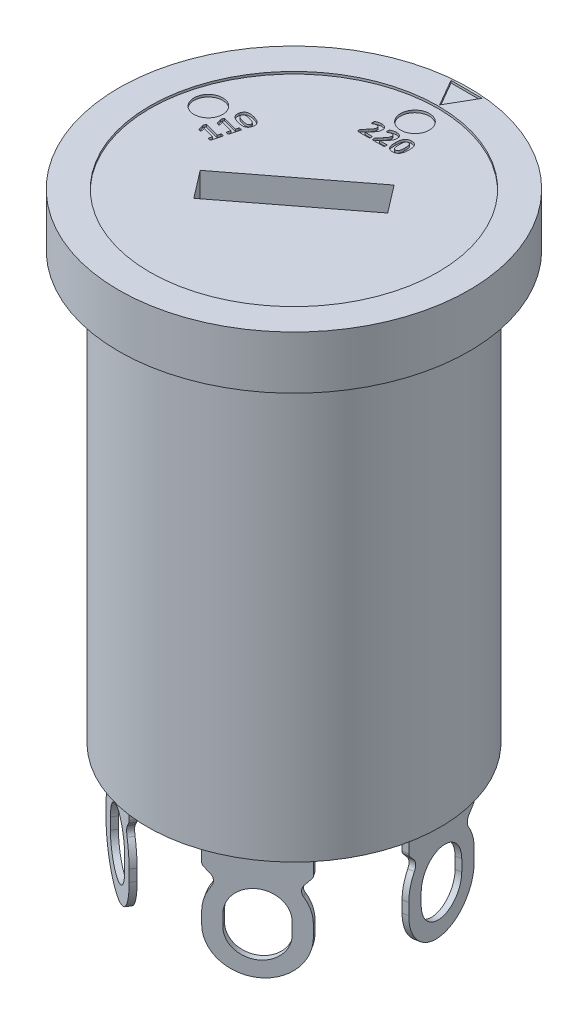
from build123d import *

# Parameters (mm, degrees)
SKETCH1_R                = 7.6
BOSS_EXTRUDE1_DEPTH      = 1.15
SKETCH2_R                = 6.35
BOSS_EXTRUDE2_DEPTH      = 18.5
BOSS_EXTRUDE3_DEPTH      = 5
CUT_EXTRUDE1_DEPTH       = 0.25
FILLET1_R                = 0.2
CIRPATTERN1_COUNT        = 4
CIRPATTERN1_ANGLE        = 200
FILLET1_OF_CIRPATTERN1_R = 0.2
SKETCH5_R                = 6.25
CUT_EXTRUDE2_DEPTH       = 0.1
CUT_EXTRUDE3_DEPTH       = 3
SKETCH7_R                = 0.625
CUT_EXTRUDE4_DEPTH       = 0.1


with BuildPart() as part:
    # Sketch1 → Boss-Extrude1 (new body, symmetric)
    with BuildSketch(Plane(origin=(0, 0, 0), x_dir=(1, 0, 0), z_dir=(0, 1, 0))):
        Circle(SKETCH1_R)
    extrude(amount=BOSS_EXTRUDE1_DEPTH, both=True)

    # Sketch2 → Boss-Extrude2 (add)
    with BuildSketch(Plane.XZ.offset(1.15)):
        Circle(SKETCH2_R)
    extrude(amount=BOSS_EXTRUDE2_DEPTH)

    # Sketch3 → Boss-Extrude3 (add)
    with BuildSketch(Plane.XZ.offset(19.65)):
        Polygon((-5.137178524, -2.682819749), (-4.890976586, -2.639407705), (-5.498745208, 0.807419431), (-5.744947146, 0.764007386), align=None)
    boss_extrude3 = extrude(amount=BOSS_EXTRUDE3_DEPTH)

    # Sketch4 → Cut-Extrude1 (cut)
    with BuildSketch(Plane(origin=(-5.441062835, 0, -0.959406182), x_dir=(-0.173648178, 0, 0.984807753), z_dir=(-0.984807753, 0, -0.173648178))):
        with BuildLine():
            Line((-1.084702388, -22.4), (-1.084702388, -22.9))
            ThreePointArc((-1.084702388, -22.9), (0, -23.984702388), (1.084702388, -22.9))
            Line((1.084702388, -22.9), (1.084702388, -22.4))
            ThreePointArc((1.084702388, -22.4), (0, -21.315297612), (-1.084702388, -22.4))
        make_face()
        with BuildLine():
            Line((1.75, -20.65), (1.474258984, -20.960255312))
            ThreePointArc((1.474258984, -20.960255312), (1.381845573, -21.181807831), (1.445322291, -21.413316933))
            ThreePointArc((1.445322291, -21.413316933), (1.672096589, -21.883673557), (1.75, -22.4))
            Line((1.75, -22.4), (1.75, -20.65))
        make_face()
        with BuildLine():
            Line((-1.75, -20.65), (-1.75, -22.4))
            ThreePointArc((-1.75, -22.4), (-1.672096589, -21.883673557), (-1.445322291, -21.413316933))
            ThreePointArc((-1.445322291, -21.413316933), (-1.381845573, -21.181807831), (-1.474258984, -20.960255312))
            Line((-1.474258984, -20.960255312), (-1.75, -20.65))
        make_face()
        with BuildLine():
            Line((-1.75, -24.65), (1e-09, -24.65))
            ThreePointArc((1e-09, -24.65), (-1.237436867, -24.137436867), (-1.75, -22.9))
            Line((-1.75, -22.9), (-1.75, -24.65))
        make_face()
        with BuildLine():
            Line((1.75, -24.65), (1.75, -22.9))
            ThreePointArc((1.75, -22.9), (1.237436867, -24.137436867), (1e-09, -24.65))
            Line((1e-09, -24.65), (1.75, -24.65))
        make_face()
    cut_extrude1 = extrude(amount=-CUT_EXTRUDE1_DEPTH, mode=Mode.SUBTRACT)

    # Fillet1
    fillet1_edges = [part.edges().sort_by_distance(p)[0] for p in [
        (-5.014077555, -20.65, -2.661113727),
        (-5.621846177, -20.65, 0.785713408),
    ]]
    fillet(fillet1_edges, radius=FILLET1_R)

    # CirPattern1: Boss-Extrude3, Cut-Extrude1 ×4 about axis
    cirpattern1_axis = Axis((0, 0, 0), (0, 1, 0))
    for i in range(1, CIRPATTERN1_COUNT):
        add(boss_extrude3.rotate(cirpattern1_axis, i * CIRPATTERN1_ANGLE / (CIRPATTERN1_COUNT - 1)))
        add(cut_extrude1.rotate(cirpattern1_axis, i * CIRPATTERN1_ANGLE / (CIRPATTERN1_COUNT - 1)), mode=Mode.SUBTRACT)

    # Fillet1 of CirPattern1
    fillet1_of_cirpattern1_edges = [part.edges().sort_by_distance(p)[0] for p in [
        (-4.429452152, -20.65, 3.54999347),
        (-1.505244812, -20.65, 5.473274893),
        (1.505244812, -20.65, 5.473274893),
        (4.429452152, -20.65, 3.54999347),
        (5.621846177, -20.65, 0.785713408),
        (5.014077555, -20.65, -2.661113727),
    ]]
    fillet(fillet1_of_cirpattern1_edges, radius=FILLET1_OF_CIRPATTERN1_R)

    # Sketch5 → Cut-Extrude2 (cut)
    with BuildSketch(Plane(origin=(0, 1.15, 0), x_dir=(1, 0, 0), z_dir=(0, 1, 0))):
        Circle(SKETCH5_R)
        Polygon((0, 6.320577137), (0.675, 7.489711432), (-0.675, 7.489711432), align=None)
    extrude(amount=-CUT_EXTRUDE2_DEPTH, mode=Mode.SUBTRACT)

    # Sketch6 → Cut-Extrude3 (cut)
    with BuildSketch(Plane(origin=(0, 1.05, 0), x_dir=(1, 0, 0), z_dir=(0, 1, 0))):
        Polygon((-2.836631093, -1.231269282), (1.923488949, 2.421299292), (2.836631093, 1.231269282), (-1.923488949, -2.421299292), align=None)
    extrude(amount=-CUT_EXTRUDE3_DEPTH, mode=Mode.SUBTRACT)

    # Sketch7 → Cut-Extrude4 (cut)
    with BuildSketch(Plane(origin=(0, 1.05, 0), x_dir=(1, 0, 0), z_dir=(0, 1, 0))):
        with Locations((0, 5.25)):
            Circle(SKETCH7_R)
        with Locations((-5.071110588, 1.358799987)):
            Circle(SKETCH7_R)
        with BuildLine():
            add(Edge.make_bspline(
                [(-3.673085561, 1.940530135), (-3.658145348, 1.936361866), (-3.62903577, 1.928240392), (-3.587140018, 1.913867484), (-3.547928097, 1.89851542), (-3.511575049, 1.881700826), (-3.478072823, 1.863870231), (-3.447977591, 1.844082858), (-3.421184433, 1.822698939), (-3.397658418, 1.799740336), (-3.377767174, 1.774961081), (-3.36157215, 1.748492487), (-3.348974447, 1.720329943), (-3.34042885, 1.690303427), (-3.335541318, 1.658374888), (-3.335406929, 1.624403585), (-3.339403169, 1.588393369), (-3.345353228, 1.564209779), (-3.348435974, 1.551680181)],
                knots=[0, 0, 0, 0, 4.6523e-05, 9.0647e-05, 0.000132813, 0.000172799, 0.000210747, 0.000246562, 0.000280686, 0.000313445, 0.000344977, 0.000375756, 0.000406294, 0.000437234, 0.000469141, 0.000502885, 0.000538857, 0.000577533, 0.000577533, 0.000577533, 0.000577533], degree=3))
            add(Edge.make_bspline(
                [(-3.348435974, 1.551680181), (-3.352064065, 1.539188901), (-3.359036652, 1.515182742), (-3.373299262, 1.481967022), (-3.390115576, 1.453021031), (-3.409383257, 1.428206666), (-3.431253127, 1.407500672), (-3.455339805, 1.390398241), (-3.481682399, 1.376783431), (-3.510246865, 1.366742302), (-3.540959073, 1.360109383), (-3.573819393, 1.356338579), (-3.608856279, 1.355442546), (-3.646016296, 1.357890469), (-3.685217038, 1.362659999), (-3.726422704, 1.369959365), (-3.769716625, 1.378974096), (-3.799022984, 1.386556399), (-3.814071027, 1.390449712)],
                knots=[0, 0, 0, 0, 3.8995e-05, 7.4942e-05, 0.000108131, 0.00013918, 0.000168853, 0.000198154, 0.000227521, 0.000257518, 0.000288715, 0.000321587, 0.000356617, 0.000393706, 0.000433205, 0.000475034, 0.000519211, 0.000565835, 0.000565835, 0.000565835, 0.000565835], degree=3))
            add(Edge.make_bspline(
                [(-3.814071027, 1.390449712), (-3.828888353, 1.394622667), (-3.857809707, 1.402767694), (-3.899525369, 1.417131822), (-3.938709652, 1.432530519), (-3.975319199, 1.449204161), (-4.008850075, 1.467515988), (-4.039112318, 1.487389119), (-4.065972279, 1.50882869), (-4.089498367, 1.53178647), (-4.109388554, 1.556566148), (-4.125587596, 1.583033856), (-4.138170368, 1.611199513), (-4.146770474, 1.641205652), (-4.151434556, 1.673170986), (-4.151298891, 1.706990564), (-4.147588964, 1.742820952), (-4.141752087, 1.766830127), (-4.138720613, 1.779299666)],
                knots=[0, 0, 0, 0, 4.6173e-05, 9.0124e-05, 0.00013229, 0.000172442, 0.000210725, 0.000246792, 0.000280916, 0.000313675, 0.000345207, 0.000375987, 0.000406524, 0.000437464, 0.000469345, 0.000503087, 0.000538677, 0.000577135, 0.000577135, 0.000577135, 0.000577135], degree=3))
            add(Edge.make_bspline(
                [(-4.138720613, 1.779299666), (-4.13502552, 1.791791386), (-4.127928963, 1.815782177), (-4.113586713, 1.848983418), (-4.097132268, 1.878172674), (-4.077702101, 1.902951358), (-4.05591877, 1.923841367), (-4.031899459, 1.941084859), (-4.005618574, 1.95479833), (-3.977007787, 1.964740999), (-3.946295273, 1.971691424), (-3.913321809, 1.975154226), (-3.878295692, 1.975898339), (-3.841129703, 1.973292872), (-3.801977935, 1.968194002), (-3.76068497, 1.961341733), (-3.71746959, 1.951922273), (-3.688139492, 1.944394058), (-3.673085561, 1.940530135)],
                knots=[0, 0, 0, 0, 3.905e-05, 7.4997e-05, 0.000108252, 0.000139301, 0.0001691, 0.000198507, 0.000227712, 0.000257709, 0.000289124, 0.000321975, 0.000357001, 0.000394101, 0.000433622, 0.000475421, 0.000519636, 0.00056626, 0.00056626, 0.00056626, 0.00056626], degree=3))
        make_face()
        with BuildLine():
            add(Edge.make_bspline(
                [(-3.707556781, 1.78112354), (-3.716367172, 1.783452413), (-3.733474209, 1.787974358), (-3.758434878, 1.794244062), (-3.781995581, 1.799464632), (-3.804033525, 1.804154135), (-3.824754464, 1.807659378), (-3.844091356, 1.811028027), (-3.862329119, 1.812836745), (-3.88411902, 1.814850337), (-3.908651563, 1.815597112), (-3.93490456, 1.813527346), (-3.957384849, 1.80896228), (-3.975917459, 1.800584592), (-3.991020091, 1.789392987), (-4.002808988, 1.775296999), (-4.011409801, 1.758422332), (-4.015133903, 1.746114382), (-4.017068212, 1.739721599)],
                knots=[0, 0, 0, 0, 2.7339e-05, 5.3084e-05, 7.7199e-05, 9.9734e-05, 0.000120665, 0.000140245, 0.000158593, 0.000175618, 0.000205903, 0.000232076, 0.00025451, 0.000274344, 0.000292583, 0.000310448, 0.000328966, 0.00034898, 0.00034898, 0.00034898, 0.00034898], degree=3))
            add(Edge.make_bspline(
                [(-4.017068212, 1.739721599), (-4.018404092, 1.734095858), (-4.020980447, 1.723246157), (-4.021794628, 1.706995335), (-4.02053717, 1.691597989), (-4.01616237, 1.677188935), (-4.009462827, 1.663554763), (-4.000128582, 1.650827817), (-3.988765504, 1.638419455), (-3.974672369, 1.627020605), (-3.95833926, 1.615993361), (-3.939509689, 1.60582433), (-3.91856731, 1.595654744), (-3.895205433, 1.58607251), (-3.869440215, 1.576908954), (-3.841562776, 1.567554024), (-3.811421877, 1.558493147), (-3.790553585, 1.552676331), (-3.779782194, 1.549673919)],
                knots=[0, 0, 0, 0, 1.7312e-05, 3.3388e-05, 4.8597e-05, 6.3428e-05, 7.8274e-05, 9.3963e-05, 0.000110613, 0.000128617, 0.000148194, 0.000169665, 0.00019275, 0.000218018, 0.000245365, 0.00027478, 0.000306225, 0.000339771, 0.000339771, 0.000339771, 0.000339771], degree=3))
            add(Edge.make_bspline(
                [(-3.779782194, 1.549673919), (-3.76672587, 1.546271163), (-3.741710461, 1.539751613), (-3.705720592, 1.531361061), (-3.673013368, 1.524691885), (-3.643500995, 1.519900578), (-3.616853915, 1.516680765), (-3.592858574, 1.515157952), (-3.571331615, 1.515236159), (-3.552268604, 1.516977086), (-3.535370946, 1.520332502), (-3.520712698, 1.525633862), (-3.508007074, 1.532392328), (-3.497348135, 1.5409295), (-3.488703373, 1.551338063), (-3.481183987, 1.562989109), (-3.475135098, 1.576289164), (-3.472285577, 1.585808257), (-3.470817925, 1.590711086)],
                knots=[0, 0, 0, 0, 4.0476e-05, 7.7551e-05, 0.000110852, 0.000140596, 0.000167224, 0.000191343, 0.000212683, 0.000231739, 0.000248694, 0.000264214, 0.000278334, 0.000291693, 0.000304888, 0.00031875, 0.000333196, 0.000348538, 0.000348538, 0.000348538, 0.000348538], degree=3))
            add(Edge.make_bspline(
                [(-3.470817925, 1.590711086), (-3.469146185, 1.598087799), (-3.465950071, 1.612190956), (-3.466632992, 1.633375654), (-3.471359248, 1.653117435), (-3.480915769, 1.671340846), (-3.494507099, 1.688446326), (-3.512865608, 1.703844069), (-3.535163931, 1.718429886), (-3.561614711, 1.732107031), (-3.591993849, 1.745545098), (-3.626821097, 1.757671262), (-3.665736918, 1.769681903), (-3.69318551, 1.777191656), (-3.707556781, 1.78112354)],
                knots=[0, 0, 0, 0, 2.261e-05, 4.3227e-05, 6.2956e-05, 8.3022e-05, 0.000104442, 0.000128103, 0.000154559, 0.000184256, 0.000217331, 0.000254137, 0.000294808, 0.000339503, 0.000339503, 0.000339503, 0.000339503], degree=3))
        make_face(mode=Mode.SUBTRACT)
        with BuildLine():
            add(Edge.make_bspline(
                [(-3.518064113, 1.210057821), (-3.512925018, 1.208631321), (-3.503517025, 1.20601987), (-3.491040011, 1.201143143), (-3.48094146, 1.196680225), (-3.473694748, 1.191413636), (-3.468438595, 1.186353541), (-3.465608599, 1.181017296), (-3.464251117, 1.175682974), (-3.464859542, 1.172244345), (-3.465171765, 1.170479754)],
                knots=[0, 0, 0, 0, 1.5985e-05, 2.9263e-05, 4.0194e-05, 4.895e-05, 5.6045e-05, 6.1838e-05, 6.6883e-05, 7.22e-05, 7.22e-05, 7.22e-05, 7.22e-05], degree=3))
            Line((-3.465171765, 1.170479754), (-3.578434345, 0.747340967))
            add(Edge.make_bspline(
                [(-3.578434345, 0.747340967), (-3.579018029, 0.745836899), (-3.580227818, 0.742719446), (-3.583872723, 0.738708316), (-3.589351047, 0.736093794), (-3.596213872, 0.733986602), (-3.605129673, 0.733481009), (-3.61608362, 0.73403912), (-3.62929967, 0.73642766), (-3.63875903, 0.738769759), (-3.643911425, 0.740045471)],
                knots=[0, 0, 0, 0, 4.815e-06, 9.98e-06, 1.5774e-05, 2.2814e-05, 3.1417e-05, 4.2374e-05, 5.5687e-05, 7.1613e-05, 7.1613e-05, 7.1613e-05, 7.1613e-05], degree=3))
            add(Edge.make_bspline(
                [(-3.643911425, 0.740045471), (-3.649153171, 0.741511848), (-3.658745305, 0.744195245), (-3.671662623, 0.748594198), (-3.681712504, 0.753502), (-3.689697168, 0.758138957), (-3.694730409, 0.763683431), (-3.698595548, 0.768685349), (-3.699675236, 0.774331278), (-3.699096928, 0.777868669), (-3.698810035, 0.779623538)],
                knots=[0, 0, 0, 0, 1.6335e-05, 2.9892e-05, 4.0823e-05, 4.9929e-05, 5.7281e-05, 6.32e-05, 6.8601e-05, 7.3919e-05, 7.3919e-05, 7.3919e-05, 7.3919e-05], degree=3))
            Line((-3.698810035, 0.779623538), (-3.660691067, 0.922432879))
            Line((-3.660691067, 0.922432879), (-4.159703015, 1.056122849))
            Line((-4.159703015, 1.056122849), (-4.124684633, 0.91459022))
            add(Edge.make_bspline(
                [(-4.124684633, 0.91459022), (-4.123885088, 0.909980743), (-4.122481657, 0.901889783), (-4.122224105, 0.891042203), (-4.124030064, 0.882450065), (-4.12987786, 0.876672398), (-4.138804446, 0.87465652), (-4.147731034, 0.875002977), (-4.156486324, 0.876564718), (-4.164741669, 0.877907612), (-4.174196567, 0.880209159), (-4.180923255, 0.881935106), (-4.184507703, 0.882854811)],
                knots=[0, 0, 0, 0, 1.4006e-05, 2.4584e-05, 3.2551e-05, 3.9515e-05, 4.7883e-05, 5.9193e-05, 6.6209e-05, 7.4546e-05, 8.4279e-05, 9.5382e-05, 9.5382e-05, 9.5382e-05, 9.5382e-05], degree=3))
            add(Edge.make_bspline(
                [(-4.184507703, 0.882854811), (-4.18883067, 0.884047791), (-4.196656791, 0.886207513), (-4.207236696, 0.889458446), (-4.215766403, 0.892704441), (-4.222580322, 0.896532534), (-4.22772993, 0.901184566), (-4.231854164, 0.906409783), (-4.234982924, 0.912791337), (-4.236662563, 0.917489069), (-4.237582438, 0.920061842)],
                knots=[0, 0, 0, 0, 1.3453e-05, 2.4356e-05, 3.3195e-05, 4.0797e-05, 4.7643e-05, 5.3882e-05, 6.0652e-05, 6.8849e-05, 6.8849e-05, 6.8849e-05, 6.8849e-05], degree=3))
            Line((-4.237582438, 0.920061842), (-4.300141319, 1.113392495))
            add(Edge.make_bspline(
                [(-4.300141319, 1.113392495), (-4.300525058, 1.114723404), (-4.301318242, 1.117474375), (-4.302218682, 1.12211569), (-4.301714849, 1.127691112), (-4.301329011, 1.134654347), (-4.299711782, 1.143237377), (-4.297182083, 1.153960499), (-4.293899044, 1.167493177), (-4.291117796, 1.177480659), (-4.28956285, 1.183064485)],
                knots=[0, 0, 0, 0, 4.159e-06, 8.597e-06, 1.4071e-05, 2.0842e-05, 2.9537e-05, 4.02e-05, 5.3913e-05, 7.1302e-05, 7.1302e-05, 7.1302e-05, 7.1302e-05], degree=3))
            add(Edge.make_bspline(
                [(-4.28956285, 1.183064485), (-4.287732094, 1.189890265), (-4.284481316, 1.202010443), (-4.279457779, 1.217990032), (-4.275228389, 1.2301249), (-4.27103755, 1.238691652), (-4.267121153, 1.244609833), (-4.26240908, 1.247541673), (-4.257499715, 1.248280931), (-4.254353042, 1.247611924), (-4.252720593, 1.247264853)],
                knots=[0, 0, 0, 0, 2.1195e-05, 3.7636e-05, 5.0273e-05, 5.9653e-05, 6.6292e-05, 7.1203e-05, 7.5821e-05, 8.0799e-05, 8.0799e-05, 8.0799e-05, 8.0799e-05], degree=3))
            Line((-4.252720593, 1.247264853), (-3.619106737, 1.077644563))
            Line((-3.619106737, 1.077644563), (-3.585547454, 1.202762325))
            add(Edge.make_bspline(
                [(-3.585547454, 1.202762325), (-3.584936083, 1.204474233), (-3.583724651, 1.207866381), (-3.579587837, 1.211938343), (-3.574030523, 1.215058199), (-3.566608782, 1.216705672), (-3.557517097, 1.217490526), (-3.546376016, 1.216280176), (-3.532983569, 1.213865225), (-3.523338825, 1.211403913), (-3.518064113, 1.210057821)],
                knots=[0, 0, 0, 0, 5.389e-06, 1.0678e-05, 1.6967e-05, 2.431e-05, 3.3277e-05, 4.4258e-05, 5.7782e-05, 7.4105e-05, 7.4105e-05, 7.4105e-05, 7.4105e-05], degree=3))
        make_face()
        with BuildLine():
            add(Edge.make_bspline(
                [(-3.684226892, 0.58992989), (-3.679087797, 0.58850339), (-3.669679804, 0.585891938), (-3.65720279, 0.581015211), (-3.647104238, 0.576552293), (-3.639857526, 0.571285704), (-3.634601374, 0.56622561), (-3.631771378, 0.560889365), (-3.630413896, 0.555555042), (-3.63102232, 0.552116413), (-3.631334544, 0.550351822)],
                knots=[0, 0, 0, 0, 1.5985e-05, 2.9263e-05, 4.0194e-05, 4.895e-05, 5.6045e-05, 6.1838e-05, 6.6883e-05, 7.22e-05, 7.22e-05, 7.22e-05, 7.22e-05], degree=3))
            Line((-3.631334544, 0.550351822), (-3.744597124, 0.127213035))
            add(Edge.make_bspline(
                [(-3.744597124, 0.127213035), (-3.745180807, 0.125708968), (-3.746390596, 0.122591514), (-3.750035502, 0.118580384), (-3.755513825, 0.115965863), (-3.762376651, 0.11385867), (-3.771292452, 0.113353077), (-3.782246399, 0.113911188), (-3.795462448, 0.116299729), (-3.804921808, 0.118641827), (-3.810074203, 0.119917539)],
                knots=[0, 0, 0, 0, 4.815e-06, 9.98e-06, 1.5774e-05, 2.2814e-05, 3.1417e-05, 4.2374e-05, 5.5687e-05, 7.1613e-05, 7.1613e-05, 7.1613e-05, 7.1613e-05], degree=3))
            add(Edge.make_bspline(
                [(-3.810074203, 0.119917539), (-3.81531595, 0.121383916), (-3.824908083, 0.124067313), (-3.837825401, 0.128466266), (-3.847875283, 0.133374069), (-3.855859947, 0.138011025), (-3.860893187, 0.143555499), (-3.864758326, 0.148557417), (-3.865838014, 0.154203346), (-3.865259707, 0.157740738), (-3.864972813, 0.159495607)],
                knots=[0, 0, 0, 0, 1.6335e-05, 2.9892e-05, 4.0823e-05, 4.9929e-05, 5.7281e-05, 6.32e-05, 6.8601e-05, 7.3919e-05, 7.3919e-05, 7.3919e-05, 7.3919e-05], degree=3))
            Line((-3.864972813, 0.159495607), (-3.826853845, 0.302304947))
            Line((-3.826853845, 0.302304947), (-4.325865794, 0.435994917))
            Line((-4.325865794, 0.435994917), (-4.290847411, 0.294462289))
            add(Edge.make_bspline(
                [(-4.290847411, 0.294462289), (-4.290047866, 0.289852811), (-4.288644435, 0.281761852), (-4.288386883, 0.270914271), (-4.290192843, 0.262322133), (-4.296040639, 0.256544466), (-4.304967225, 0.254528589), (-4.313893812, 0.254875045), (-4.322649103, 0.256436786), (-4.330904447, 0.25777968), (-4.340359345, 0.260081227), (-4.347086034, 0.261807175), (-4.350670481, 0.26272688)],
                knots=[0, 0, 0, 0, 1.4006e-05, 2.4584e-05, 3.2551e-05, 3.9515e-05, 4.7883e-05, 5.9193e-05, 6.6209e-05, 7.4546e-05, 8.4279e-05, 9.5382e-05, 9.5382e-05, 9.5382e-05, 9.5382e-05], degree=3))
            add(Edge.make_bspline(
                [(-4.350670481, 0.26272688), (-4.354993449, 0.26391986), (-4.36281957, 0.266079581), (-4.373399475, 0.269330515), (-4.381929181, 0.272576509), (-4.3887431, 0.276404602), (-4.393892709, 0.281056635), (-4.398016942, 0.286281852), (-4.401145702, 0.292663406), (-4.402825341, 0.297361137), (-4.403745217, 0.299933911)],
                knots=[0, 0, 0, 0, 1.3453e-05, 2.4356e-05, 3.3195e-05, 4.0797e-05, 4.7643e-05, 5.3882e-05, 6.0652e-05, 6.8849e-05, 6.8849e-05, 6.8849e-05, 6.8849e-05], degree=3))
            Line((-4.403745217, 0.299933911), (-4.466304098, 0.493264563))
            add(Edge.make_bspline(
                [(-4.466304098, 0.493264563), (-4.466687837, 0.494595472), (-4.467481021, 0.497346443), (-4.468381461, 0.501987758), (-4.467877628, 0.50756318), (-4.467491789, 0.514526415), (-4.465874561, 0.523109446), (-4.463344861, 0.533832568), (-4.460061822, 0.547365245), (-4.457280575, 0.557352727), (-4.455725628, 0.562936553)],
                knots=[0, 0, 0, 0, 4.159e-06, 8.597e-06, 1.4071e-05, 2.0842e-05, 2.9537e-05, 4.02e-05, 5.3913e-05, 7.1302e-05, 7.1302e-05, 7.1302e-05, 7.1302e-05], degree=3))
            add(Edge.make_bspline(
                [(-4.455725628, 0.562936553), (-4.453894872, 0.569762333), (-4.450644095, 0.581882511), (-4.445620558, 0.597862101), (-4.441391167, 0.609996968), (-4.437200328, 0.618563721), (-4.433283932, 0.624481902), (-4.428571859, 0.627413741), (-4.423662494, 0.628153), (-4.42051582, 0.627483992), (-4.418883372, 0.627136921)],
                knots=[0, 0, 0, 0, 2.1195e-05, 3.7636e-05, 5.0273e-05, 5.9653e-05, 6.6292e-05, 7.1203e-05, 7.5821e-05, 8.0799e-05, 8.0799e-05, 8.0799e-05, 8.0799e-05], degree=3))
            Line((-4.418883372, 0.627136921), (-3.785269516, 0.457516631))
            Line((-3.785269516, 0.457516631), (-3.751710233, 0.582634393))
            add(Edge.make_bspline(
                [(-3.751710233, 0.582634393), (-3.751098862, 0.584346302), (-3.74988743, 0.58773845), (-3.745750616, 0.591810411), (-3.740193301, 0.594930267), (-3.73277156, 0.596577741), (-3.723679876, 0.597362594), (-3.712538794, 0.596152245), (-3.699146348, 0.593737293), (-3.689501603, 0.591275981), (-3.684226892, 0.58992989)],
                knots=[0, 0, 0, 0, 5.389e-06, 1.0678e-05, 1.6967e-05, 2.431e-05, 3.3277e-05, 4.4258e-05, 5.7782e-05, 7.4105e-05, 7.4105e-05, 7.4105e-05, 7.4105e-05], degree=3))
        make_face()
        with BuildLine():
            add(Edge.make_bspline(
                [(-0.367693015, 3.714565142), (-0.367720313, 3.709148665), (-0.36777071, 3.699149058), (-0.369172904, 3.685408241), (-0.370730441, 3.673966595), (-0.373508673, 3.664910665), (-0.376745599, 3.657760608), (-0.381572878, 3.653076958), (-0.387179952, 3.650600006), (-0.391077588, 3.650201261), (-0.393044864, 3.65)],
                knots=[0, 0, 0, 0, 1.6237e-05, 2.9975e-05, 4.1429e-05, 5.0776e-05, 5.8362e-05, 6.4682e-05, 7.0479e-05, 7.6386e-05, 7.6386e-05, 7.6386e-05, 7.6386e-05], degree=3))
            Line((-0.393044864, 3.65), (-0.853208295, 3.65))
            add(Edge.make_bspline(
                [(-0.853208295, 3.65), (-0.857468038, 3.650088655), (-0.865425958, 3.650254278), (-0.87654221, 3.651865076), (-0.885959822, 3.655508519), (-0.893615037, 3.661692731), (-0.898971277, 3.670929361), (-0.90251394, 3.683080677), (-0.90425773, 3.69864812), (-0.904504773, 3.710184477), (-0.904641544, 3.716571404)],
                knots=[0, 0, 0, 0, 1.2779e-05, 2.3873e-05, 3.3526e-05, 4.2727e-05, 5.28e-05, 6.5029e-05, 8.048e-05, 9.9645e-05, 9.9645e-05, 9.9645e-05, 9.9645e-05], degree=3))
            add(Edge.make_bspline(
                [(-0.904641544, 3.716571404), (-0.90451322, 3.722773716), (-0.904276392, 3.734220455), (-0.903171496, 3.750228441), (-0.900668367, 3.764035213), (-0.896573656, 3.776342211), (-0.890674605, 3.787469145), (-0.88380878, 3.79866123), (-0.874721253, 3.809899218), (-0.867843319, 3.817411756), (-0.86415154, 3.821444164)],
                knots=[0, 0, 0, 0, 1.8612e-05, 3.4349e-05, 4.8085e-05, 6.0601e-05, 7.3081e-05, 8.5782e-05, 9.9939e-05, 0.000116343, 0.000116343, 0.000116343, 0.000116343], degree=3))
            Line((-0.86415154, 3.821444164), (-0.72900247, 3.96662454))
            add(Edge.make_bspline(
                [(-0.72900247, 3.96662454), (-0.722580217, 3.973642133), (-0.710161004, 3.987212599), (-0.692818508, 4.007412717), (-0.677498174, 4.026709373), (-0.664105263, 4.045060988), (-0.652311406, 4.062528719), (-0.642023722, 4.079170173), (-0.632919408, 4.094997347), (-0.623012628, 4.114563674), (-0.613438118, 4.137583161), (-0.605930475, 4.164001522), (-0.601996773, 4.188526861), (-0.601424584, 4.204324234), (-0.601148897, 4.211935604)],
                knots=[0, 0, 0, 0, 2.8537e-05, 5.5184e-05, 7.9852e-05, 0.000102433, 0.000123325, 0.000143064, 0.000161117, 0.000178083, 0.000208837, 0.000235744, 0.000260302, 0.000283136, 0.000283136, 0.000283136, 0.000283136], degree=3))
            add(Edge.make_bspline(
                [(-0.601148897, 4.211935604), (-0.601471974, 4.218046495), (-0.60211198, 4.230151996), (-0.606974784, 4.247562721), (-0.614810107, 4.263585418), (-0.626178312, 4.277376326), (-0.640480073, 4.289044416), (-0.658245494, 4.297355324), (-0.679137946, 4.302808839), (-0.694188461, 4.303375272), (-0.702191521, 4.303676471)],
                knots=[0, 0, 0, 0, 1.8312e-05, 3.6276e-05, 5.3813e-05, 7.1445e-05, 8.9476e-05, 0.000108727, 0.000129828, 0.00015379, 0.00015379, 0.00015379, 0.00015379], degree=3))
            add(Edge.make_bspline(
                [(-0.702191521, 4.303676471), (-0.708031206, 4.303573399), (-0.719370218, 4.303373263), (-0.73591358, 4.301767117), (-0.751378967, 4.298812715), (-0.770213941, 4.293792789), (-0.791398684, 4.285950652), (-0.813937165, 4.275398677), (-0.832986223, 4.264743982), (-0.846716515, 4.25646049), (-0.855853747, 4.250442991), (-0.861813498, 4.247808007), (-0.86686657, 4.245677222), (-0.870154523, 4.245425442), (-0.871629423, 4.2453125)],
                knots=[0, 0, 0, 0, 1.7518e-05, 3.4014e-05, 4.979e-05, 6.4699e-05, 9.2451e-05, 0.000117419, 0.000139297, 0.000157877, 0.000165572, 0.000172018, 0.000177441, 0.000181852, 0.000181852, 0.000181852, 0.000181852], degree=3))
            add(Edge.make_bspline(
                [(-0.871629423, 4.2453125), (-0.873378938, 4.245468987), (-0.876902662, 4.245784169), (-0.881622821, 4.249161787), (-0.885315283, 4.254610275), (-0.887915209, 4.262550799), (-0.889963408, 4.273087286), (-0.891797997, 4.286602082), (-0.892796436, 4.303297052), (-0.892908002, 4.3154696), (-0.89296875, 4.322097599)],
                knots=[0, 0, 0, 0, 5.188e-06, 1.0448e-05, 1.6724e-05, 2.4687e-05, 3.5311e-05, 4.893e-05, 6.5564e-05, 8.5447e-05, 8.5447e-05, 8.5447e-05, 8.5447e-05], degree=3))
            add(Edge.make_bspline(
                [(-0.89296875, 4.322097599), (-0.89296622, 4.326598498), (-0.892961635, 4.334756543), (-0.892161193, 4.346010271), (-0.891171956, 4.35541287), (-0.889531288, 4.363421608), (-0.887332115, 4.370271028), (-0.884451692, 4.37664223), (-0.879828864, 4.382995018), (-0.874598169, 4.388734116), (-0.868522516, 4.393823878), (-0.862156325, 4.398291291), (-0.85422119, 4.403294471), (-0.840706404, 4.410533686), (-0.820718106, 4.42025533), (-0.792934879, 4.430764594), (-0.761346603, 4.440494345), (-0.726630687, 4.448741199), (-0.689484969, 4.454440085), (-0.663911457, 4.455092096), (-0.650940659, 4.455422794)],
                knots=[0, 0, 0, 0, 1.3498e-05, 2.4465e-05, 3.3831e-05, 4.1844e-05, 4.8938e-05, 5.5384e-05, 6.2721e-05, 7.2401e-05, 7.8613e-05, 8.6457e-05, 9.5718e-05, 0.000106737, 0.000132434, 0.000162342, 0.000195745, 0.000231534, 0.000269322, 0.000308213, 0.000308213, 0.000308213, 0.000308213], degree=3))
            add(Edge.make_bspline(
                [(-0.650940659, 4.455422794), (-0.640840598, 4.455275256), (-0.621263943, 4.454989288), (-0.592848155, 4.452001203), (-0.566391079, 4.447228485), (-0.54196441, 4.440187078), (-0.519508462, 4.431648818), (-0.498902697, 4.421656519), (-0.480393856, 4.409932059), (-0.463836353, 4.396699641), (-0.449251295, 4.382160874), (-0.436594659, 4.366210516), (-0.426094867, 4.348893518), (-0.417446248, 4.330367486), (-0.410958659, 4.310806509), (-0.406248656, 4.290536501), (-0.403156945, 4.269543037), (-0.402861589, 4.255294083), (-0.402711397, 4.248048311)],
                knots=[0, 0, 0, 0, 3.029e-05, 5.871e-05, 8.5611e-05, 0.000110839, 0.000134855, 0.000157612, 0.000179421, 0.000200442, 0.000221077, 0.000241073, 0.000261374, 0.000281692, 0.000302282, 0.000323075, 0.000344071, 0.000365794, 0.000365794, 0.000365794, 0.000365794], degree=3))
            add(Edge.make_bspline(
                [(-0.402711397, 4.248048311), (-0.40306839, 4.235202567), (-0.403780544, 4.20957703), (-0.408438679, 4.177655116), (-0.414319969, 4.152033828), (-0.421141295, 4.132250616), (-0.429433564, 4.111558356), (-0.440207646, 4.090224044), (-0.452875849, 4.067794182), (-0.467869354, 4.04430813), (-0.485247745, 4.019687714), (-0.505147634, 3.993823107), (-0.527781892, 3.966223449), (-0.553695565, 3.936723387), (-0.583134161, 3.905216282), (-0.604086544, 3.883720001), (-0.61501034, 3.872512638)],
                knots=[0, 0, 0, 0, 3.8527e-05, 7.6856e-05, 9.6542e-05, 0.000117305, 0.000139557, 0.000163375, 0.000188938, 0.000216817, 0.000246925, 0.000279319, 0.000314699, 0.00035399, 0.000397092, 0.000444043, 0.000444043, 0.000444043, 0.000444043], degree=3))
            Line((-0.61501034, 3.872512638), (-0.706204044, 3.778400735))
            Line((-0.706204044, 3.778400735), (-0.395051126, 3.778400735))
            add(Edge.make_bspline(
                [(-0.395051126, 3.778400735), (-0.393067892, 3.778232552), (-0.389085417, 3.777894828), (-0.38356515, 3.774793893), (-0.378499283, 3.770178577), (-0.374541585, 3.763211376), (-0.37121184, 3.754320005), (-0.369303557, 3.743016541), (-0.367740709, 3.729565031), (-0.36770966, 3.719800258), (-0.367693015, 3.714565142)],
                knots=[0, 0, 0, 0, 5.907e-06, 1.1862e-05, 1.8573e-05, 2.6268e-05, 3.5618e-05, 4.6957e-05, 6.0532e-05, 7.6222e-05, 7.6222e-05, 7.6222e-05, 7.6222e-05], degree=3))
        make_face()
        with BuildLine():
            add(Edge.make_bspline(
                [(0.274310662, 3.714565142), (0.274283363, 3.709148665), (0.274232967, 3.699149058), (0.272830773, 3.685408241), (0.271273235, 3.673966595), (0.268495003, 3.664910665), (0.265258077, 3.657760608), (0.260430798, 3.653076958), (0.254823724, 3.650600006), (0.250926088, 3.650201261), (0.248958812, 3.65)],
                knots=[0, 0, 0, 0, 1.6237e-05, 2.9975e-05, 4.1429e-05, 5.0776e-05, 5.8362e-05, 6.4682e-05, 7.0479e-05, 7.6386e-05, 7.6386e-05, 7.6386e-05, 7.6386e-05], degree=3))
            Line((0.248958812, 3.65), (-0.211204619, 3.65))
            add(Edge.make_bspline(
                [(-0.211204619, 3.65), (-0.215464361, 3.650088655), (-0.223422281, 3.650254278), (-0.234538533, 3.651865076), (-0.243956146, 3.655508519), (-0.251611361, 3.661692731), (-0.256967601, 3.670929361), (-0.260510263, 3.683080677), (-0.262254054, 3.69864812), (-0.262501096, 3.710184477), (-0.262637868, 3.716571404)],
                knots=[0, 0, 0, 0, 1.2779e-05, 2.3873e-05, 3.3526e-05, 4.2727e-05, 5.28e-05, 6.5029e-05, 8.048e-05, 9.9645e-05, 9.9645e-05, 9.9645e-05, 9.9645e-05], degree=3))
            add(Edge.make_bspline(
                [(-0.262637868, 3.716571404), (-0.262509544, 3.722773716), (-0.262272715, 3.734220455), (-0.261167819, 3.750228441), (-0.258664691, 3.764035213), (-0.25456998, 3.776342211), (-0.248670928, 3.787469145), (-0.241805103, 3.79866123), (-0.232717577, 3.809899218), (-0.225839642, 3.817411756), (-0.222147863, 3.821444164)],
                knots=[0, 0, 0, 0, 1.8612e-05, 3.4349e-05, 4.8085e-05, 6.0601e-05, 7.3081e-05, 8.5782e-05, 9.9939e-05, 0.000116343, 0.000116343, 0.000116343, 0.000116343], degree=3))
            Line((-0.222147863, 3.821444164), (-0.086998794, 3.96662454))
            add(Edge.make_bspline(
                [(-0.086998794, 3.96662454), (-0.08057654, 3.973642133), (-0.068157327, 3.987212599), (-0.050814831, 4.007412717), (-0.035494497, 4.026709373), (-0.022101586, 4.045060988), (-0.010307729, 4.062528719), (-2.0045e-05, 4.079170173), (0.009084268, 4.094997347), (0.018991048, 4.114563674), (0.028565558, 4.137583161), (0.036073202, 4.164001522), (0.040006904, 4.188526861), (0.040579092, 4.204324234), (0.040854779, 4.211935604)],
                knots=[0, 0, 0, 0, 2.8537e-05, 5.5184e-05, 7.9852e-05, 0.000102433, 0.000123325, 0.000143064, 0.000161117, 0.000178083, 0.000208837, 0.000235744, 0.000260302, 0.000283136, 0.000283136, 0.000283136, 0.000283136], degree=3))
            add(Edge.make_bspline(
                [(0.040854779, 4.211935604), (0.040531703, 4.218046495), (0.039891696, 4.230151996), (0.035028893, 4.247562721), (0.02719357, 4.263585418), (0.015825364, 4.277376326), (0.001523603, 4.289044416), (-0.016241817, 4.297355324), (-0.03713427, 4.302808839), (-0.052184784, 4.303375272), (-0.060187845, 4.303676471)],
                knots=[0, 0, 0, 0, 1.8312e-05, 3.6276e-05, 5.3813e-05, 7.1445e-05, 8.9476e-05, 0.000108727, 0.000129828, 0.00015379, 0.00015379, 0.00015379, 0.00015379], degree=3))
            add(Edge.make_bspline(
                [(-0.060187845, 4.303676471), (-0.06602753, 4.303573399), (-0.077366541, 4.303373263), (-0.093909903, 4.301767117), (-0.109375291, 4.298812715), (-0.128210265, 4.293792789), (-0.149395008, 4.285950652), (-0.171933488, 4.275398677), (-0.190982547, 4.264743982), (-0.204712839, 4.25646049), (-0.21385007, 4.250442991), (-0.219809822, 4.247808007), (-0.224862893, 4.245677222), (-0.228150847, 4.245425442), (-0.229625747, 4.2453125)],
                knots=[0, 0, 0, 0, 1.7518e-05, 3.4014e-05, 4.979e-05, 6.4699e-05, 9.2451e-05, 0.000117419, 0.000139297, 0.000157877, 0.000165572, 0.000172018, 0.000177441, 0.000181852, 0.000181852, 0.000181852, 0.000181852], degree=3))
            add(Edge.make_bspline(
                [(-0.229625747, 4.2453125), (-0.231375261, 4.245468987), (-0.234898985, 4.245784169), (-0.239619145, 4.249161787), (-0.243311606, 4.254610275), (-0.245911533, 4.262550799), (-0.247959731, 4.273087286), (-0.24979432, 4.286602082), (-0.25079276, 4.303297052), (-0.250904326, 4.3154696), (-0.250965074, 4.322097599)],
                knots=[0, 0, 0, 0, 5.188e-06, 1.0448e-05, 1.6724e-05, 2.4687e-05, 3.5311e-05, 4.893e-05, 6.5564e-05, 8.5447e-05, 8.5447e-05, 8.5447e-05, 8.5447e-05], degree=3))
            add(Edge.make_bspline(
                [(-0.250965074, 4.322097599), (-0.250962544, 4.326598498), (-0.250957958, 4.334756543), (-0.250157516, 4.346010271), (-0.24916828, 4.35541287), (-0.247527611, 4.363421608), (-0.245328439, 4.370271028), (-0.242448015, 4.37664223), (-0.237825187, 4.382995018), (-0.232594493, 4.388734116), (-0.22651884, 4.393823878), (-0.220152648, 4.398291291), (-0.212217514, 4.403294471), (-0.198702728, 4.410533686), (-0.178714429, 4.42025533), (-0.150931203, 4.430764594), (-0.119342927, 4.440494345), (-0.08462701, 4.448741199), (-0.047481293, 4.454440085), (-0.02190778, 4.455092096), (-0.008936983, 4.455422794)],
                knots=[0, 0, 0, 0, 1.3498e-05, 2.4465e-05, 3.3831e-05, 4.1844e-05, 4.8938e-05, 5.5384e-05, 6.2721e-05, 7.2401e-05, 7.8613e-05, 8.6457e-05, 9.5718e-05, 0.000106737, 0.000132434, 0.000162342, 0.000195745, 0.000231534, 0.000269322, 0.000308213, 0.000308213, 0.000308213, 0.000308213], degree=3))
            add(Edge.make_bspline(
                [(-0.008936983, 4.455422794), (0.001163078, 4.455275256), (0.020739733, 4.454989288), (0.049155522, 4.452001203), (0.075612597, 4.447228485), (0.100039267, 4.440187078), (0.122495215, 4.431648818), (0.14310098, 4.421656519), (0.16160982, 4.409932059), (0.178167323, 4.396699641), (0.192752381, 4.382160874), (0.205409018, 4.366210516), (0.21590881, 4.348893518), (0.224557428, 4.330367486), (0.231045017, 4.310806509), (0.23575502, 4.290536501), (0.238846732, 4.269543037), (0.239142087, 4.255294083), (0.239292279, 4.248048311)],
                knots=[0, 0, 0, 0, 3.029e-05, 5.871e-05, 8.5611e-05, 0.000110839, 0.000134855, 0.000157612, 0.000179421, 0.000200442, 0.000221077, 0.000241073, 0.000261374, 0.000281692, 0.000302282, 0.000323075, 0.000344071, 0.000365794, 0.000365794, 0.000365794, 0.000365794], degree=3))
            add(Edge.make_bspline(
                [(0.239292279, 4.248048311), (0.238935286, 4.235202567), (0.238223133, 4.20957703), (0.233564997, 4.177655116), (0.227683708, 4.152033828), (0.220862382, 4.132250616), (0.212570112, 4.111558356), (0.20179603, 4.090224044), (0.189127828, 4.067794182), (0.174134323, 4.04430813), (0.156755931, 4.019687714), (0.136856042, 3.993823107), (0.114221785, 3.966223449), (0.088308111, 3.936723387), (0.058869516, 3.905216282), (0.037917132, 3.883720001), (0.026993336, 3.872512638)],
                knots=[0, 0, 0, 0, 3.8527e-05, 7.6856e-05, 9.6542e-05, 0.000117305, 0.000139557, 0.000163375, 0.000188938, 0.000216817, 0.000246925, 0.000279319, 0.000314699, 0.00035399, 0.000397092, 0.000444043, 0.000444043, 0.000444043, 0.000444043], degree=3))
            Line((0.026993336, 3.872512638), (-0.064200368, 3.778400735))
            Line((-0.064200368, 3.778400735), (0.246952551, 3.778400735))
            add(Edge.make_bspline(
                [(0.246952551, 3.778400735), (0.248935785, 3.778232552), (0.252918259, 3.777894828), (0.258438526, 3.774793893), (0.263504394, 3.770178577), (0.267462092, 3.763211376), (0.270791836, 3.754320005), (0.27270012, 3.743016541), (0.274262968, 3.729565031), (0.274294016, 3.719800258), (0.274310662, 3.714565142)],
                knots=[0, 0, 0, 0, 5.907e-06, 1.1862e-05, 1.8573e-05, 2.6268e-05, 3.5618e-05, 4.6957e-05, 6.0532e-05, 7.6222e-05, 7.6222e-05, 7.6222e-05, 7.6222e-05], degree=3))
        make_face()
        with BuildLine():
            add(Edge.make_bspline(
                [(0.927987132, 4.049975586), (0.92783382, 4.03458958), (0.92753478, 4.004578611), (0.924577036, 3.960685894), (0.919662998, 3.919115852), (0.913049422, 3.879849855), (0.904266658, 3.843060784), (0.892746601, 3.809011792), (0.878928434, 3.777697891), (0.862743148, 3.749183311), (0.843767942, 3.723807862), (0.822396249, 3.70127407), (0.798025433, 3.682235172), (0.77113384, 3.666149158), (0.741338736, 3.653493463), (0.708401702, 3.644572158), (0.672387187, 3.639340505), (0.647310718, 3.638672591), (0.634343405, 3.638327206)],
                knots=[0, 0, 0, 0, 4.6153e-05, 9.0023e-05, 0.000131898, 0.000171688, 0.000209421, 0.000245238, 0.000279368, 0.000311967, 0.000343374, 0.000374204, 0.000404854, 0.000435852, 0.000467967, 0.00050164, 0.000537957, 0.000576849, 0.000576849, 0.000576849, 0.000576849], degree=3))
            add(Edge.make_bspline(
                [(0.634343405, 3.638327206), (0.621195146, 3.638680372), (0.596007826, 3.639356912), (0.559928971, 3.644379883), (0.527438712, 3.653071246), (0.498347563, 3.665212333), (0.47242281, 3.680638261), (0.449757837, 3.699573755), (0.429291536, 3.720986551), (0.412223369, 3.74597702), (0.397568643, 3.773732383), (0.385486163, 3.804373439), (0.375305595, 3.837752814), (0.368111321, 3.874083926), (0.362777975, 3.913024792), (0.358764143, 3.954396289), (0.356372733, 3.998270583), (0.356139873, 4.028329228), (0.356020221, 4.043774414)],
                knots=[0, 0, 0, 0, 3.9438e-05, 7.5549e-05, 0.000108997, 0.000140059, 0.000169837, 0.000199122, 0.000228411, 0.000258414, 0.000289581, 0.0003224, 0.000357077, 0.000394134, 0.000433366, 0.000474962, 0.000518799, 0.000565131, 0.000565131, 0.000565131, 0.000565131], degree=3))
            add(Edge.make_bspline(
                [(0.356020221, 4.043774414), (0.356142986, 4.059102173), (0.356382454, 4.089000834), (0.359767683, 4.13273377), (0.364216399, 4.174302629), (0.371173572, 4.213600036), (0.380152194, 4.250474233), (0.391536081, 4.284650215), (0.405486572, 4.315916326), (0.421690397, 4.34439476), (0.440533669, 4.369994843), (0.462167805, 4.392409898), (0.486517483, 4.411525813), (0.513424023, 4.427597018), (0.543214408, 4.440260613), (0.576038489, 4.449133069), (0.611859179, 4.454427685), (0.636756427, 4.455083038), (0.649663948, 4.455422794)],
                knots=[0, 0, 0, 0, 4.5971e-05, 8.9671e-05, 0.000131525, 0.000171346, 0.0002093, 0.00024529, 0.000279254, 0.000311853, 0.000343406, 0.000374363, 0.000405012, 0.00043601, 0.000468125, 0.000501798, 0.000537755, 0.000576464, 0.000576464, 0.000576464, 0.000576464], degree=3))
            add(Edge.make_bspline(
                [(0.649663948, 4.455422794), (0.662817876, 4.455173784), (0.688087454, 4.45469542), (0.72414827, 4.44924953), (0.756873117, 4.440941509), (0.785988174, 4.428499154), (0.812039788, 4.413088504), (0.835097952, 4.394488779), (0.855173938, 4.372682494), (0.872362392, 4.347798482), (0.886950486, 4.3200024), (0.899172516, 4.289445015), (0.908762283, 4.255923889), (0.916102009, 4.219676267), (0.921461449, 4.180733345), (0.92517675, 4.139342332), (0.927652814, 4.095480957), (0.927873656, 4.065421295), (0.927987132, 4.049975586)],
                knots=[0, 0, 0, 0, 3.943e-05, 7.5747e-05, 0.000109149, 0.00014045, 0.000170384, 0.000199695, 0.000228993, 0.000258996, 0.000290163, 0.000322982, 0.000357555, 0.000394613, 0.000433845, 0.000475423, 0.00051926, 0.000565593, 0.000565593, 0.000565593, 0.000565593], degree=3))
        make_face()
        with BuildLine():
            add(Edge.make_bspline(
                [(0.764568015, 4.041768153), (0.764528825, 4.050826726), (0.764453068, 4.068337691), (0.763990333, 4.093821102), (0.762775231, 4.117585093), (0.761635169, 4.139856415), (0.759765523, 4.160588565), (0.757587047, 4.179926744), (0.755134995, 4.197840445), (0.751013012, 4.219042212), (0.745663514, 4.242688244), (0.736662745, 4.267215969), (0.726336079, 4.287554997), (0.713165575, 4.303073802), (0.69837966, 4.314884966), (0.681317549, 4.322139459), (0.662713842, 4.326460716), (0.64968982, 4.326829988), (0.642915614, 4.327022059)],
                knots=[0, 0, 0, 0, 2.7176e-05, 5.2534e-05, 7.6452e-05, 9.8558e-05, 0.00011943, 0.000138886, 0.000156942, 0.000173647, 0.000203683, 0.000229535, 0.000251893, 0.000271696, 0.000290156, 0.000308119, 0.000326834, 0.00034712, 0.00034712, 0.00034712, 0.00034712], degree=3))
            add(Edge.make_bspline(
                [(0.642915614, 4.327022059), (0.637059209, 4.326839075), (0.625793589, 4.326487081), (0.609727301, 4.32303903), (0.595038742, 4.317912143), (0.582141207, 4.310002636), (0.570526489, 4.300174827), (0.56058475, 4.287898226), (0.551537988, 4.273755888), (0.54394864, 4.257406402), (0.537647356, 4.238959986), (0.532165594, 4.218495939), (0.52785106, 4.195815282), (0.524664564, 4.171018517), (0.522336986, 4.144118625), (0.520785785, 4.115101509), (0.519617955, 4.083969752), (0.519500091, 4.062500726), (0.519439338, 4.051434685)],
                knots=[0, 0, 0, 0, 1.7543e-05, 3.3747e-05, 4.9096e-05, 6.3985e-05, 7.8861e-05, 9.4531e-05, 0.000111177, 0.000129126, 0.00014845, 0.000169597, 0.000192633, 0.000217654, 0.00024457, 0.000273616, 0.000304823, 0.00033802, 0.00033802, 0.00033802, 0.00033802], degree=3))
            add(Edge.make_bspline(
                [(0.519439338, 4.051434685), (0.519490936, 4.038058762), (0.519589467, 4.012515966), (0.520824823, 3.976018629), (0.523050481, 3.943121242), (0.525778799, 3.913636494), (0.529822625, 3.887405666), (0.534677115, 3.864120508), (0.540465483, 3.843617776), (0.547092063, 3.825751813), (0.554987876, 3.810542141), (0.563947429, 3.797833546), (0.573862702, 3.787350755), (0.585020681, 3.779332872), (0.597397375, 3.773632297), (0.610754373, 3.769754479), (0.625172902, 3.766992028), (0.635180397, 3.766818034), (0.64036219, 3.766727941)],
                knots=[0, 0, 0, 0, 4.0127e-05, 7.6627e-05, 0.000109529, 0.000139038, 0.000165427, 0.000189107, 0.000210352, 0.000229287, 0.000246175, 0.00026161, 0.000275798, 0.000289262, 0.000302561, 0.000316467, 0.00033092, 0.000346441, 0.000346441, 0.000346441, 0.000346441], degree=3))
            add(Edge.make_bspline(
                [(0.64036219, 3.766727941), (0.648002279, 3.767022222), (0.662605287, 3.7675847), (0.683212237, 3.773407281), (0.701239972, 3.783036393), (0.716557637, 3.796951803), (0.729571666, 3.814468123), (0.739886915, 3.836056015), (0.748288127, 3.861079177), (0.75498135, 3.889786553), (0.759812081, 3.922234777), (0.762721164, 3.958611484), (0.764272516, 3.998892804), (0.764466605, 4.027054126), (0.764568015, 4.041768153)],
                knots=[0, 0, 0, 0, 2.2871e-05, 4.3715e-05, 6.3628e-05, 8.3652e-05, 0.000105283, 0.000128693, 0.000155109, 0.000184351, 0.000217007, 0.000253434, 0.000293775, 0.000337916, 0.000337916, 0.000337916, 0.000337916], degree=3))
        make_face(mode=Mode.SUBTRACT)
    extrude(amount=-CUT_EXTRUDE4_DEPTH, mode=Mode.SUBTRACT)


solid = part.part
